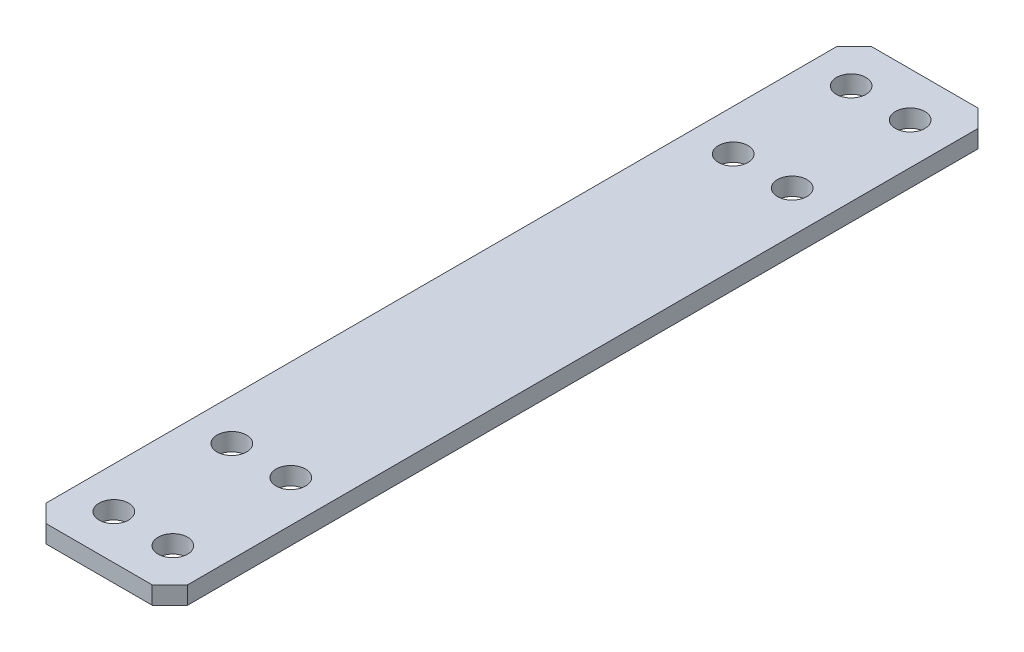
from build123d import *

# Parameters (mm, degrees)
SKETCH_1_R      = 2.5
EXTRUDE_1_DEPTH = 3


with BuildPart() as part:
    # 草圖1 → 填料-伸長1 (new body)
    with BuildSketch(Plane(origin=(0, 3, 0), x_dir=(1, 0, 0), z_dir=(0, 1, 0))):
        Polygon((-12, 67), (-12, -67), (-9, -70), (9, -70), (12, -67), (12, 67), (9, 70), (-9, 70), align=None)
        with Locations((-5, 62.5)):
            Circle(SKETCH_1_R, mode=Mode.SUBTRACT)
        with Locations((5, 62.5)):
            Circle(SKETCH_1_R, mode=Mode.SUBTRACT)
        with Locations((5, 42.5)):
            Circle(SKETCH_1_R, mode=Mode.SUBTRACT)
        with Locations((-5, 42.5)):
            Circle(SKETCH_1_R, mode=Mode.SUBTRACT)
        with Locations((5, -42.5)):
            Circle(SKETCH_1_R, mode=Mode.SUBTRACT)
        with Locations((-5, -42.5)):
            Circle(SKETCH_1_R, mode=Mode.SUBTRACT)
        with Locations((5, -62.5)):
            Circle(SKETCH_1_R, mode=Mode.SUBTRACT)
        with Locations((-5, -62.5)):
            Circle(SKETCH_1_R, mode=Mode.SUBTRACT)
    extrude(amount=-EXTRUDE_1_DEPTH)


solid = part.part
